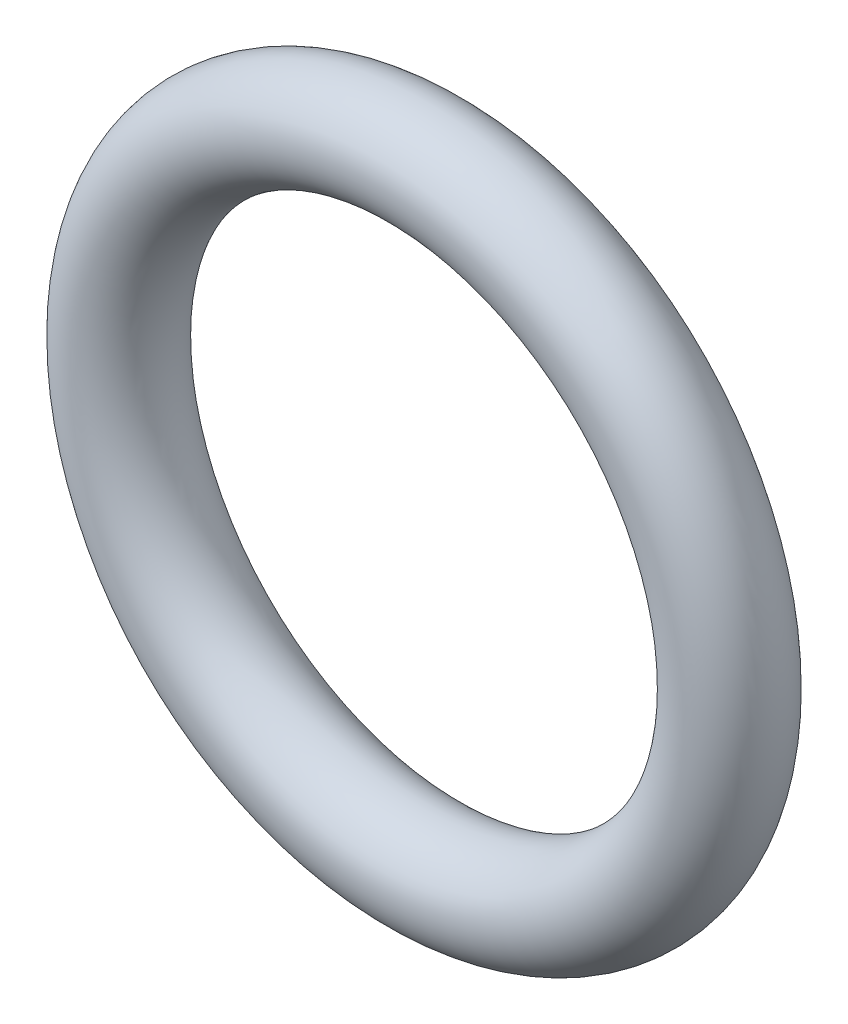
from build123d import *

# Parameters (mm, degrees)
SKETCH1_R = 1


with BuildPart() as part:
    # Sketch1 → Revolve1 (revolve)
    with BuildSketch(Plane(origin=(0, 0, 0), x_dir=(0, 0, -1), z_dir=(1, 0, 0))):
        with Locations((0, 6)):
            Circle(SKETCH1_R)
    revolve(axis=Axis((0, 0, 24.264405023), (0, 0, -1)))


solid = part.part
